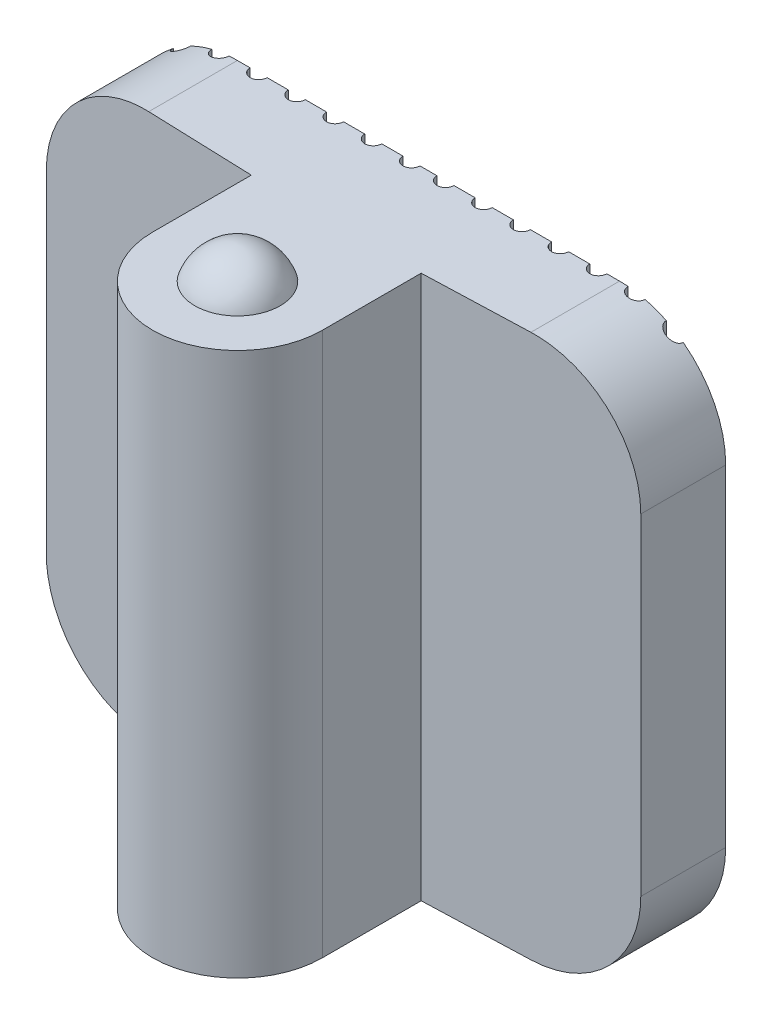
from build123d import *

# Parameters (mm, degrees)
SKETCH1_W               = 14
SKETCH1_H               = 12.8
BOSS_EXTRUDE1_DEPTH     = 2
BOSS_EXTRUDE3_DEPTH     = 12.8
CUT_EXTRUDE1_DEPTH      = 1
CUT_EXTRUDE1_DEPTH_BACK = 14
FILLET3_R               = 2.5
FILLET4_R               = 2.5


with BuildPart() as part:
    # Sketch1 → Boss-Extrude1 (new body)
    with BuildSketch(Plane.XY):
        with Locations((7, 6.4)):
            Rectangle(SKETCH1_W, SKETCH1_H)
    extrude(amount=BOSS_EXTRUDE1_DEPTH)

    # Sketch2 → Boss-Extrude3 (add)
    with BuildSketch(Plane.XZ):
        Polygon((5.00259729, 2.174694547), (0, 2), (5.00259729, 2), align=None)
        with BuildLine():
            Line((5.00259729, 4.5), (5.00259729, 2.174694547))
            Line((5.00259729, 2.174694547), (5.00259729, 2))
            Line((5.00259729, 2), (9.00259729, 2))
            Line((9.00259729, 2), (9.00259729, 2.174513148))
            Line((9.00259729, 2.174513148), (9.00259729, 4.5))
            ThreePointArc((9.00259729, 4.5), (7.00259729, 6.5), (5.00259729, 4.5))
        make_face()
        Polygon((9.00259729, 2.174513148), (9.00259729, 2), (14, 2), align=None)
    extrude(amount=-BOSS_EXTRUDE3_DEPTH)

    # Sketch3 → Cut-Extrude1 (cut, two sides)
    with BuildSketch(Plane.XZ) as cut_extrude1_sk:
        with BuildLine():
            ThreePointArc((13, 0), (12.8, 0.2), (12.6, 0))
            Line((12.6, 0), (13, 0))
        make_face()
        with BuildLine():
            ThreePointArc((12.1, 0), (11.9, 0.2), (11.7, 0))
            Line((11.7, 0), (12.1, 0))
        make_face()
        with BuildLine():
            ThreePointArc((11.2, 0), (11, 0.2), (10.8, 0))
            Line((10.8, 0), (11.2, 0))
        make_face()
        with BuildLine():
            ThreePointArc((10.3, 0), (10.1, 0.2), (9.9, 0))
            Line((9.9, 0), (10.3, 0))
        make_face()
        with BuildLine():
            ThreePointArc((9.4, 0), (9.2, 0.2), (9, 0))
            Line((9, 0), (9.4, 0))
        make_face()
        with BuildLine():
            ThreePointArc((8.5, 0), (8.3, 0.2), (8.1, 0))
            Line((8.1, 0), (8.5, 0))
        make_face()
        with BuildLine():
            ThreePointArc((7.6, 0), (7.4, 0.2), (7.2, 0))
            Line((7.2, 0), (7.6, 0))
        make_face()
        with BuildLine():
            ThreePointArc((6.8, 0), (6.6, 0.2), (6.4, 0))
            Line((6.4, 0), (6.8, 0))
        make_face()
        with BuildLine():
            ThreePointArc((5.9, 0), (5.7, 0.2), (5.5, 0))
            Line((5.5, 0), (5.9, 0))
        make_face()
        with BuildLine():
            ThreePointArc((5, 0), (4.8, 0.2), (4.6, 0))
            Line((4.6, 0), (5, 0))
        make_face()
        with BuildLine():
            ThreePointArc((4.1, 0), (3.9, 0.2), (3.7, 0))
            Line((3.7, 0), (4.1, 0))
        make_face()
        with BuildLine():
            ThreePointArc((3.2, 0), (3, 0.2), (2.8, 0))
            Line((2.8, 0), (3.2, 0))
        make_face()
        with BuildLine():
            ThreePointArc((2.3, 0), (2.1, 0.2), (1.9, 0))
            Line((1.9, 0), (2.3, 0))
        make_face()
        with BuildLine():
            ThreePointArc((1.4, 0), (1.2, 0.2), (1, 0))
            Line((1, 0), (1.4, 0))
        make_face()
    extrude(amount=CUT_EXTRUDE1_DEPTH, mode=Mode.SUBTRACT)
    extrude(cut_extrude1_sk.sketch, amount=-CUT_EXTRUDE1_DEPTH_BACK, mode=Mode.SUBTRACT)

    # Fillet3
    fillet3_edges = [part.edges().sort_by_distance(p)[0] for p in [
        (0, 0, 1),
    ]]
    fillet(fillet3_edges, radius=FILLET3_R)

    # Fillet4
    fillet4_edges = [part.edges().sort_by_distance(p)[0] for p in [
        (0, 12.8, 1),
        (14, 12.8, 1),
        (14, 0, 1),
    ]]
    fillet(fillet4_edges, radius=FILLET4_R)

    # Sketch8 → Revolve3 (revolve)
    with BuildSketch(Plane(origin=(7.00259729, 0, 0), x_dir=(0, 0, -1), z_dir=(1, 0, 0))):
        with BuildLine():
            Line((-5.500754281, 0), (-4.5, 0))
            Line((-4.5, 0), (-4.5, -0.75))
            ThreePointArc((-4.5, -0.75), (-5.123268888, -0.538979256), (-5.500754281, 0))
        make_face()
    revolve(axis=Axis((7.00259729, -0.75, 4.5), (0, 1, 0)))

    # Sketch11 → Revolve4 (revolve)
    with BuildSketch(Plane(origin=(7.00259729, 0, 0), x_dir=(0, 0, -1), z_dir=(1, 0, 0))):
        with BuildLine():
            Line((-3.495153371, 12.8), (-4.5, 12.8))
            Line((-4.5, 12.8), (-4.5, 13.55))
            ThreePointArc((-4.5, 13.55), (-3.879071275, 13.333773017), (-3.495153371, 12.8))
        make_face()
    revolve(axis=Axis((7.00259729, 12.8, 4.5), (0, 1, 0)))


solid = part.part
